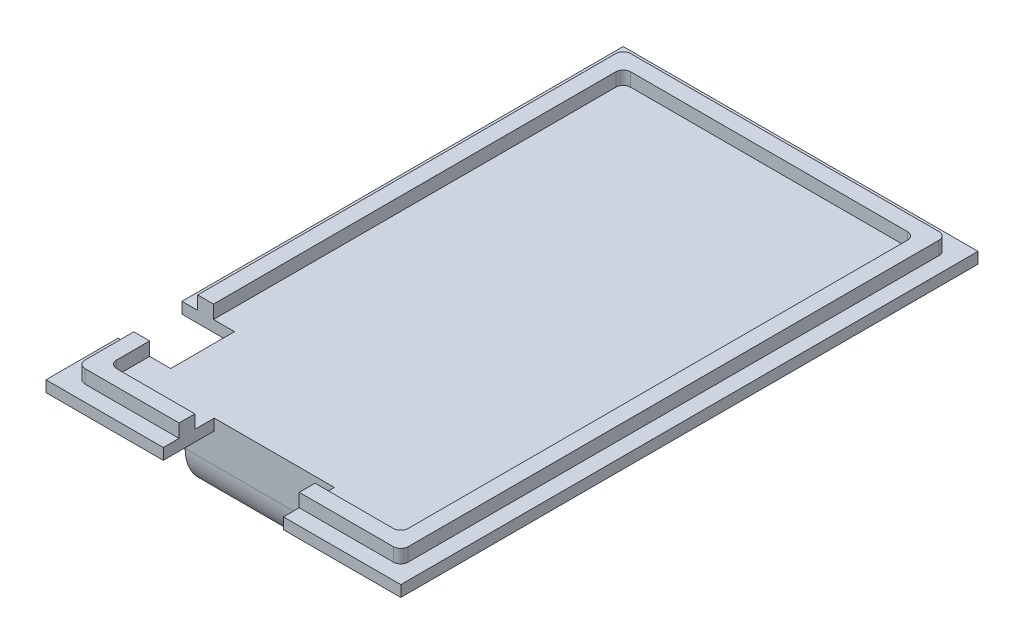
from build123d import *

# Parameters (mm, degrees)
PCB_DIMENSIONS_W    = 47.716732244
PCB_DIMENSIONS_H    = 77.636732244
BOSS_EXTRUDE3_DEPTH = 1.5
SKETCH5_W           = 43.474091557
SKETCH5_H           = 73.394091557
SKETCH5_W_2         = 39.23145087
SKETCH5_H_2         = 69.15145087
BOSS_EXTRUDE4_DEPTH = 1.8
FILLET1_R           = 1
SKETCH6_W           = 12
SKETCH6_H           = 31.966906412
SKETCH6_H_2         = 32.033093588
BOSS_EXTRUDE5_DEPTH = 10
SKETCH7_W           = 48
SKETCH7_H           = 6
CUT_EXTRUDE1_DEPTH  = 24
FILLET2_R           = 6
FILLET3_R           = 1
SCALE1_SCALE        = 0.99
CUT_EXTRUDE2_DEPTH  = 10
SKETCH9_W           = 7
SKETCH9_H           = 8.5
CUT_EXTRUDE3_DEPTH  = 10


with BuildPart() as part:
    # PCB Dimensions → Boss-Extrude3 (new body)
    with BuildSketch(Plane(origin=(0, 0, 0), x_dir=(1, 0, 0), z_dir=(0, 1, 0))):
        with Locations((20.322832216, -35.282832216)):
            Rectangle(PCB_DIMENSIONS_W, PCB_DIMENSIONS_H)
    extrude(amount=BOSS_EXTRUDE3_DEPTH)

    # Sketch5 → Boss-Extrude4 (add)
    with BuildSketch(Plane(origin=(0, 1.5, 0), x_dir=(1, 0, 0), z_dir=(0, 1, 0))):
        with Locations((20.322832217, -35.282832217)):
            Rectangle(SKETCH5_W, SKETCH5_H)
        with Locations((20.322832216, -35.282832216)):
            Rectangle(SKETCH5_W_2, SKETCH5_H_2, mode=Mode.SUBTRACT)
    extrude(amount=BOSS_EXTRUDE4_DEPTH)

    # Fillet1
    fillet1_edges = [part.edges().sort_by_distance(p)[0] for p in [
        (-1.414213562, 2.4, -1.414213562),
        (-1.414213562, 2.4, 71.979877995),
        (42.059877995, 2.4, 71.979877995),
        (42.059877995, 2.4, -1.414213562),
        (0.707106781, 2.4, 0.707106781),
        (0.707106781, 2.4, 69.858557651),
        (39.938557651, 2.4, 69.858557651),
        (39.938557651, 2.4, 0.707106781),
    ]]
    fillet(fillet1_edges, radius=FILLET1_R)

    # Sketch6 → Boss-Extrude5 (add)
    with BuildSketch(Plane.XZ):
        with Locations((14.322832216, 51.266285422)):
            Rectangle(SKETCH6_W, SKETCH6_H)
        with Locations((26.322832216, 51.266285422)):
            Rectangle(SKETCH6_W, SKETCH6_H)
        with Locations((14.322832216, 19.266285422)):
            Rectangle(SKETCH6_W, SKETCH6_H_2)
        with Locations((26.322832216, 19.266285422)):
            Rectangle(SKETCH6_W, SKETCH6_H_2)
    extrude(amount=BOSS_EXTRUDE5_DEPTH)

    # Sketch7 → Cut-Extrude1 (cut)
    with BuildSketch(Plane(origin=(32.322832216, 0, 0), x_dir=(0, 0, -1), z_dir=(1, 0, 0))):
        with Locations((-35.249738628, -3)):
            Rectangle(SKETCH7_W, SKETCH7_H)
    extrude(amount=-CUT_EXTRUDE1_DEPTH, mode=Mode.SUBTRACT)

    # Fillet2
    fillet2_edges = [part.edges().sort_by_distance(p)[0] for p in [
        (20.322832216, -10, 67.249738628),
        (20.322832216, -10, 3.249738628),
    ]]
    fillet(fillet2_edges, radius=FILLET2_R)

    # Fillet3
    fillet3_edges = [part.edges().sort_by_distance(p)[0] for p in [
        (20.322832216, -6, 59.249738628),
        (20.322832216, -6, 11.249738628),
    ]]
    fillet(fillet3_edges, radius=FILLET3_R)


with BuildPart() as part_1:
    # Scale1: scaled about (20.322832216, -3.218350849, 35.264379677)
    add(part.part.scale(SCALE1_SCALE).moved(Location((0.203228322, -0.032183508, 0.352643797))))

    # Sketch8 → Cut-Extrude2 (cut)
    with BuildSketch(Plane.XZ.offset(0.032183508)):
        Polygon((20.322832216, 73.712830152), (12.322832216, 73.712830152), (12.322832216, 66.929885038), (28.322832216, 66.929885038), (28.322832216, 73.712830152), align=None)
    extrude(amount=-CUT_EXTRUDE2_DEPTH, mode=Mode.SUBTRACT)

    # Sketch9 → Cut-Extrude3 (cut)
    with BuildSketch(Plane.XZ.offset(0.032183508)):
        with Locations((0.203049755, 59.862830152)):
            Rectangle(SKETCH9_W, SKETCH9_H)
    extrude(amount=-CUT_EXTRUDE3_DEPTH, mode=Mode.SUBTRACT)


solid = part_1.part
